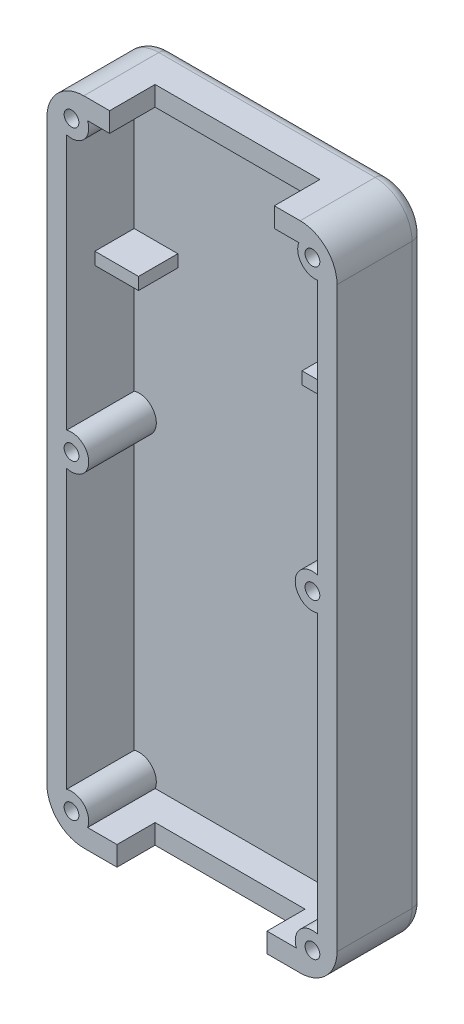
from build123d import *

# Parameters (mm, degrees)
SKETCH1_W           = 23.6
SKETCH1_H           = 53
BOSS_EXTRUDE2_DEPTH = 7.1
SHELL1_T            = -1.6
FILLET2_R           = 3
SKETCH7_W           = 12.2
SKETCH7_H           = 1.6
CUT_EXTRUDE1_DEPTH  = 3.1
SKETCH8_W           = 13.4
SKETCH8_H           = 1.6
CUT_EXTRUDE2_DEPTH  = 3.7
SKETCH9_W           = 3.55
SKETCH9_H           = 1
BOSS_EXTRUDE3_DEPTH = 3.2
SKETCH10_R          = 1.4
BOSS_EXTRUDE4_DEPTH = 7.1
SKETCH11_R          = 0.6
CUT_EXTRUDE4_DEPTH  = 7.1
FILLET3_R           = 1


with BuildPart() as part:
    # Sketch1 → Boss-Extrude2 (new body)
    with BuildSketch(Plane.XY):
        with Locations((-28.818351302, -28.026390465)):
            Rectangle(SKETCH1_W, SKETCH1_H)
    extrude(amount=BOSS_EXTRUDE2_DEPTH)

    # Shell1
    shell1_openings = [part.faces().sort_by_distance(p)[0] for p in [
        (-28.818351302, -28.026390465, 7.1),
    ]]
    offset(amount=SHELL1_T, openings=shell1_openings, kind=Kind.INTERSECTION)

    # Fillet2
    fillet2_edges = [part.edges().sort_by_distance(p)[0] for p in [
        (-40.618351302, -1.526390465, 3.55),
        (-17.018351302, -1.526390465, 3.55),
        (-17.018351302, -54.526390465, 3.55),
        (-40.618351302, -54.526390465, 3.55),
    ]]
    fillet(fillet2_edges, radius=FILLET2_R)

    # Sketch7 → Cut-Extrude1 (cut)
    with BuildSketch(Plane.XY.offset(7.1)):
        with Locations((-28.818351302, -53.726390465)):
            Rectangle(SKETCH7_W, SKETCH7_H)
    extrude(amount=-CUT_EXTRUDE1_DEPTH, mode=Mode.SUBTRACT)

    # Sketch8 → Cut-Extrude2 (cut)
    with BuildSketch(Plane.XY.offset(7.1)):
        with Locations((-28.818351302, -2.326390465)):
            Rectangle(SKETCH8_W, SKETCH8_H)
    extrude(amount=-CUT_EXTRUDE2_DEPTH, mode=Mode.SUBTRACT)

    # Sketch9 → Boss-Extrude3 (add)
    with BuildSketch(Plane.XY.offset(1.6)):
        with Locations((-20.393351302, -14.826390465)):
            Rectangle(SKETCH9_W, SKETCH9_H)
        with Locations((-37.243351302, -14.826390465)):
            Rectangle(SKETCH9_W, SKETCH9_H)
    extrude(amount=BOSS_EXTRUDE3_DEPTH)

    # Sketch10 → Boss-Extrude4 (add)
    with BuildSketch(Plane.XY.offset(7.1)):
        with Locations((-38.618351302, -52.426390465)):
            Circle(SKETCH10_R)
        with Locations((-19.018351302, -52.426390465)):
            Circle(SKETCH10_R)
        with Locations((-38.618351302, -27.126390465)):
            Circle(SKETCH10_R)
        with Locations((-19.018351302, -27.126390465)):
            Circle(SKETCH10_R)
        with Locations((-18.818351302, -3.626390465)):
            Circle(SKETCH10_R)
        with Locations((-38.618351302, -3.626390465)):
            Circle(SKETCH10_R)
    extrude(amount=-BOSS_EXTRUDE4_DEPTH)

    # Sketch11 → Cut-Extrude4 (cut)
    with BuildSketch(Plane.XY.offset(7.1)):
        with Locations((-38.618351302, -3.626390465)):
            Circle(SKETCH11_R)
        with Locations((-19.018351302, -3.626390465)):
            Circle(SKETCH11_R)
        with Locations((-38.618351302, -52.426390465)):
            Circle(SKETCH11_R)
        with Locations((-19.018351302, -52.426390465)):
            Circle(SKETCH11_R)
        with Locations((-38.618351302, -27.126390465)):
            Circle(SKETCH11_R)
        with Locations((-19.018351302, -27.126390465)):
            Circle(SKETCH11_R)
    extrude(amount=-CUT_EXTRUDE4_DEPTH, mode=Mode.SUBTRACT)

    # Fillet3
    fillet3_edges = [part.edges().sort_by_distance(p)[0] for p in [
        (-28.818351302, -1.526390465, 0),
        (-40.618351302, -28.026390465, 0),
        (-17.018351302, -28.026390465, 0),
        (-28.818351302, -54.526390465, 0),
        (-39.739671646, -2.405070122, 0),
        (-39.739671646, -53.647710809, 0),
        (-17.897030959, -53.647710809, 0),
        (-17.897030959, -2.405070122, 0),
    ]]
    fillet(fillet3_edges, radius=FILLET3_R)


solid = part.part
